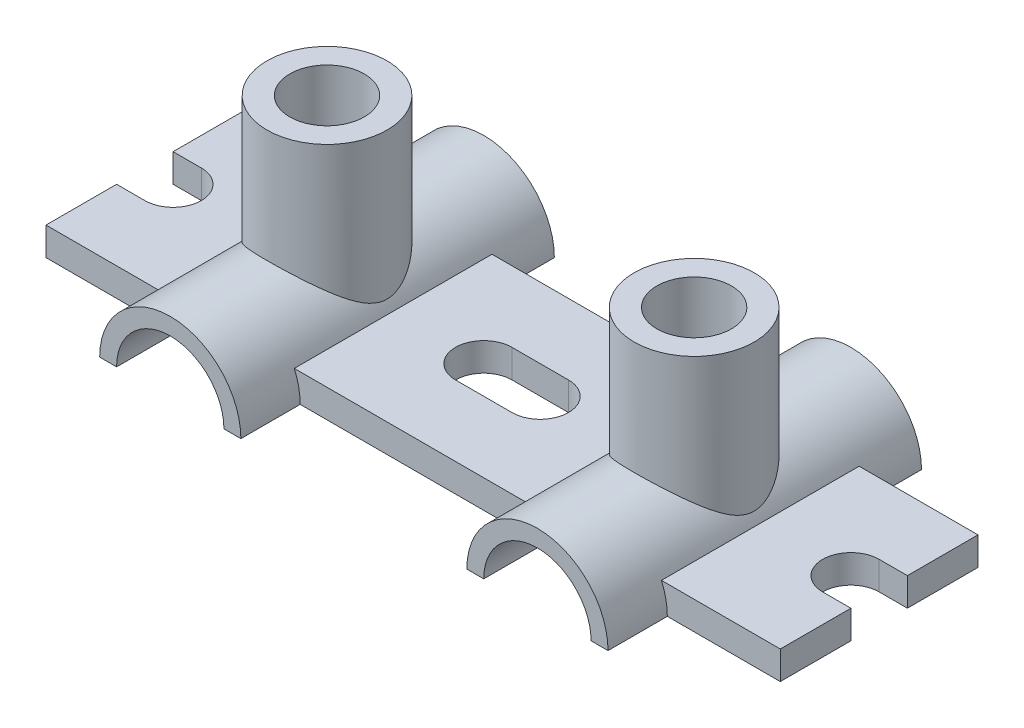
from build123d import *

# Parameters (mm, degrees)
BOSS_EXTRUDE1_DEPTH      = 110
CUT_EXTRUDE3_START       = -11
SKETCH3_W                = 42.087121525
SKETCH3_H                = 20
CUT_EXTRUDE3_DEPTH       = 27
BOSS_EXTRUDE4_DEPTH      = 20
BOSS_EXTRUDE4_DEPTH_BACK = 91
BOSS_EXTRUDE5_REACH      = 67
SKETCH8_R                = 21.258333205
SKETCH8_R_2              = 13.198570557
SKETCH9_R                = 13.198570557
CUT_EXTRUDE4_DEPTH       = 49


with BuildPart() as part:
    # Sketch2 → Boss-Extrude1 (new body)
    with BuildSketch(Plane.XY):
        with BuildLine():
            Line((-65, 0), (-19, 0))
            ThreePointArc((-19, 0), (0, 19), (19, 0))
            Line((19, 0), (65, 0))
            Line((65, 0), (65, 10))
            Line((65, 10), (22.912878475, 10))
            ThreePointArc((22.912878475, 10), (0, 25), (-22.912878475, 10))
            Line((-22.912878475, 10), (-65, 10))
            Line((-65, 10), (-65, 0))
        make_face()
    extrude(amount=BOSS_EXTRUDE1_DEPTH)

    # Sketch3 → Cut-Extrude3 (cut)
    with BuildSketch(Plane(origin=(0, 10, 0), x_dir=(1, 0, 0), z_dir=(0, 1, 0)).offset(CUT_EXTRUDE3_START)):
        with Locations((43.956439237, -10)):
            Rectangle(SKETCH3_W, SKETCH3_H)
        with BuildLine():
            Line((65, -55), (65, -45))
            Line((65, -45), (55, -45))
            ThreePointArc((55, -45), (45, -55), (55, -65))
            Line((55, -65), (65, -65))
            Line((65, -65), (65, -55))
        make_face()
        with Locations((43.956439237, -100)):
            Rectangle(SKETCH3_W, SKETCH3_H)
    cut_extrude3 = extrude(amount=CUT_EXTRUDE3_DEPTH, mode=Mode.SUBTRACT)

    # Mirror1: Cut-Extrude3 across plane
    add(cut_extrude3.mirror(Plane(origin=(0, 0, 0), x_dir=(0, 0, 1), z_dir=(1, 0, 0))), mode=Mode.SUBTRACT)

    # Sketch7 → Boss-Extrude4 (add, two sides)
    with BuildSketch(Plane(origin=(0, 0, 20), x_dir=(-1, 0, 0), z_dir=(0, 0, -1))) as boss_extrude4_sk:
        with BuildLine():
            Line((-25, 0), (-19, 0))
            ThreePointArc((-19, 0), (0, 19), (19, 0))
            Line((19, 0), (25, 0))
            ThreePointArc((25, 0), (0, 25), (-25, 0))
        make_face()
    extrude(amount=BOSS_EXTRUDE4_DEPTH)
    extrude(boss_extrude4_sk.sketch, amount=-BOSS_EXTRUDE4_DEPTH_BACK)

    # Sketch8 → Boss-Extrude5 (add, up to next)
    with BuildSketch(Plane(origin=(0, 65, 0), x_dir=(1, 0, 0), z_dir=(0, 1, 0)), mode=Mode.PRIVATE) as boss_extrude5_sk1:
        with Locations((0, -55.5)):
            Circle(SKETCH8_R)
        with Locations((0, -55.5)):
            Circle(SKETCH8_R_2, mode=Mode.SUBTRACT)
    boss_extrude5_tool1 = extrude(boss_extrude5_sk1.sketch, amount=-BOSS_EXTRUDE5_REACH, mode=Mode.PRIVATE) - part.part
    add(boss_extrude5_tool1.solids().sort_by_distance((-20.657057, 65, 55.5))[0])

    # Sketch9 → Cut-Extrude4 (cut)
    with BuildSketch(Plane(origin=(0, 65, 0), x_dir=(1, 0, 0), z_dir=(0, 1, 0))):
        with Locations((0, -55.5)):
            Circle(SKETCH9_R)
    extrude(amount=-CUT_EXTRUDE4_DEPTH, mode=Mode.SUBTRACT)

    # Mirror2: part across plane


with BuildPart() as part_1:
    add(part.part)
    add(part.part.mirror(Plane(origin=(65, 0, 0), x_dir=(0, 0, 1), z_dir=(1, 0, 0))))


solid = part_1.part
